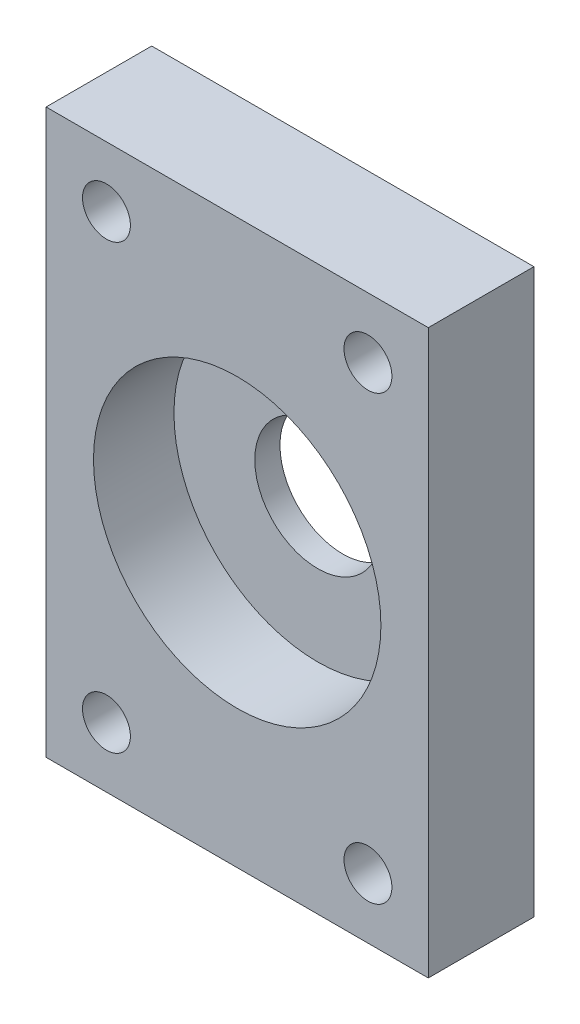
from build123d import *

# Parameters (mm, degrees)
CROQUIS1_R              = 18.2875
CROQUIS1_R_2            = 14.2875
SALIENTE_EXTRUIR1_DEPTH = 8
CROQUIS2_W              = 38
CROQUIS2_H              = 56
CROQUIS2_R              = 18.2875
SALIENTE_EXTRUIR2_DEPTH = 8
CROQUIS5_W              = 38
CROQUIS5_H              = 56
CROQUIS5_R              = 6.25
SALIENTE_EXTRUIR3_DEPTH = 2.5
CROQUIS7_R              = 2.38125
CORTAR_EXTRUIR3_DEPTH   = 11.5


with BuildPart() as part:
    # Croquis1 → Saliente-Extruir1 (new body)
    with BuildSketch(Plane.XY):
        Circle(CROQUIS1_R)
        Circle(CROQUIS1_R_2, mode=Mode.SUBTRACT)
    extrude(amount=SALIENTE_EXTRUIR1_DEPTH)

    # Croquis2 → Saliente-Extruir2 (add)
    with BuildSketch(Plane(origin=(0, 0, 0), x_dir=(-1, 0, 0), z_dir=(0, 0, -1))):
        Rectangle(CROQUIS2_W, CROQUIS2_H)
        Circle(CROQUIS2_R, mode=Mode.SUBTRACT)
    extrude(amount=-SALIENTE_EXTRUIR2_DEPTH)

    # Croquis5 → Saliente-Extruir3 (add)
    with BuildSketch(Plane(origin=(0, 0, 0), x_dir=(-1, 0, 0), z_dir=(0, 0, -1))):
        Rectangle(CROQUIS5_W, CROQUIS5_H)
        Circle(CROQUIS5_R, mode=Mode.SUBTRACT)
    extrude(amount=SALIENTE_EXTRUIR3_DEPTH)

    # Croquis7 → Cortar-Extruir3 (cut, through all)
    with BuildSketch(Plane(origin=(0, 0, -2.5), x_dir=(-1, 0, 0), z_dir=(0, 0, -1))):
        with Locations((-13, 22)):
            Circle(CROQUIS7_R)
        with Locations((13, 22)):
            Circle(CROQUIS7_R)
        with Locations((13, -22)):
            Circle(CROQUIS7_R)
        with Locations((-13, -22)):
            Circle(CROQUIS7_R)
    extrude(amount=-CORTAR_EXTRUIR3_DEPTH, mode=Mode.SUBTRACT)


solid = part.part
